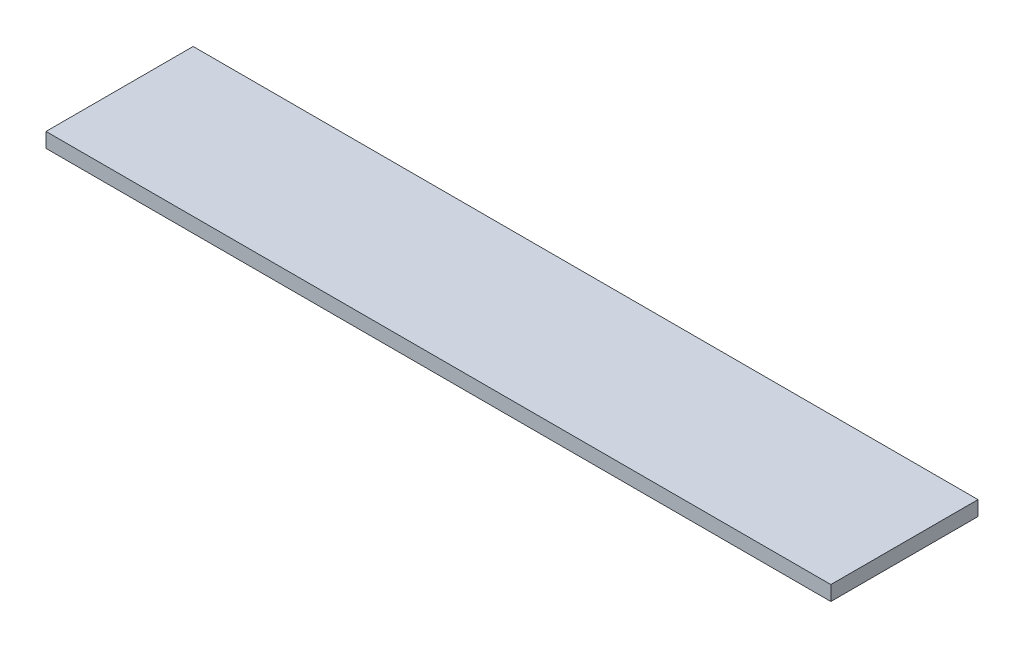
from build123d import *

# Parameters (mm, degrees)
SKETCH1_W           = 10.16
SKETCH1_H           = 1.905
BOSS_EXTRUDE1_DEPTH = 0.1905


with BuildPart() as part:
    # Sketch1 → Boss-Extrude1 (new body)
    with BuildSketch(Plane(origin=(0, 0, 0), x_dir=(1, 0, 0), z_dir=(0, 1, 0))):
        with Locations((5.08, 0.9525)):
            Rectangle(SKETCH1_W, SKETCH1_H)
    extrude(amount=BOSS_EXTRUDE1_DEPTH)


solid = part.part
